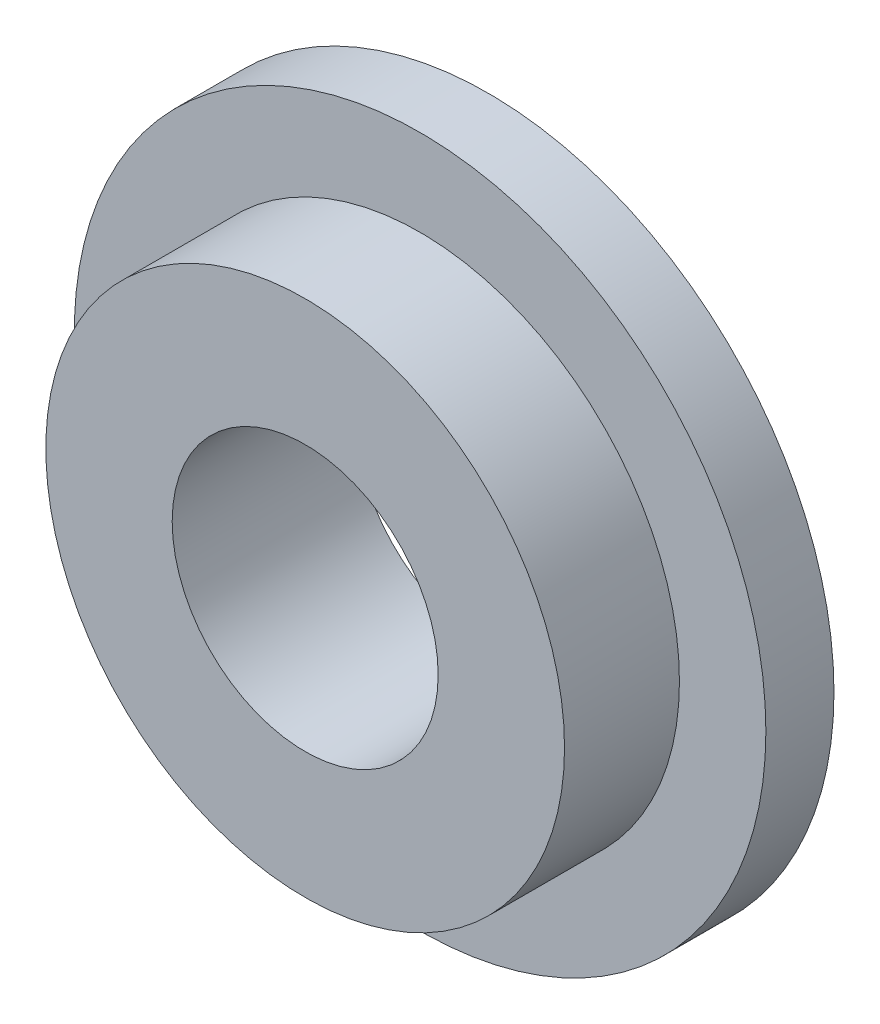
from build123d import *

# Parameters (mm, degrees)
SKETCH1_R           = 20.6375
SKETCH1_R_2         = 7.9375
BOSS_EXTRUDE1_DEPTH = 4.064
SKETCH2_R           = 15.47876
SKETCH2_R_2         = 7.9375
BOSS_EXTRUDE2_DEPTH = 6.858


with BuildPart() as part:
    # Sketch1 → Boss-Extrude1 (new body)
    with BuildSketch(Plane.XY):
        Circle(SKETCH1_R)
        Circle(SKETCH1_R_2, mode=Mode.SUBTRACT)
    extrude(amount=BOSS_EXTRUDE1_DEPTH)

    # Sketch2 → Boss-Extrude2 (add)
    with BuildSketch(Plane.XY.offset(4.064)):
        Circle(SKETCH2_R)
        Circle(SKETCH2_R_2, mode=Mode.SUBTRACT)
    extrude(amount=BOSS_EXTRUDE2_DEPTH)


solid = part.part
